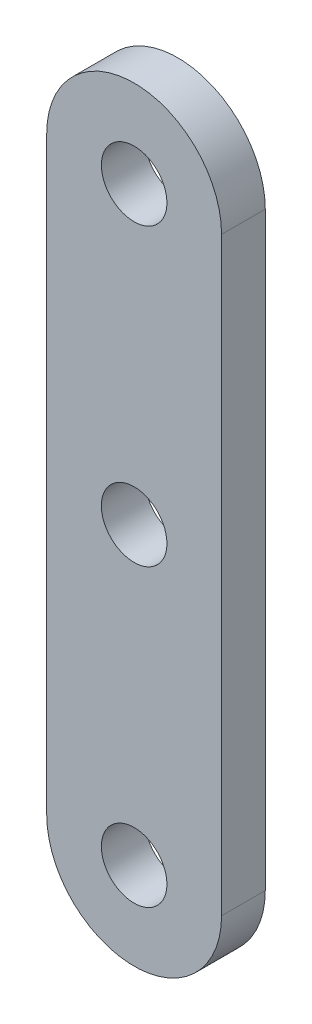
from build123d import *

# Parameters (mm, degrees)
SKETCH1_R           = 2.38125
BOSS_EXTRUDE1_DEPTH = 3.175


with BuildPart() as part:
    # Sketch1 → Boss-Extrude1 (new body)
    with BuildSketch(Plane.XY):
        with BuildLine():
            Line((-6.35, 0), (-6.35, 42.8625))
            ThreePointArc((-6.35, 42.8625), (0, 49.2125), (6.35, 42.8625))
            Line((6.35, 42.8625), (6.35, 0))
            ThreePointArc((6.35, 0), (0, -6.35), (-6.35, 0))
        make_face()
        Circle(SKETCH1_R, mode=Mode.SUBTRACT)
        with Locations((0, 42.8625)):
            Circle(SKETCH1_R, mode=Mode.SUBTRACT)
        with Locations((0, 21.43125)):
            Circle(SKETCH1_R, mode=Mode.SUBTRACT)
    extrude(amount=BOSS_EXTRUDE1_DEPTH)


solid = part.part
